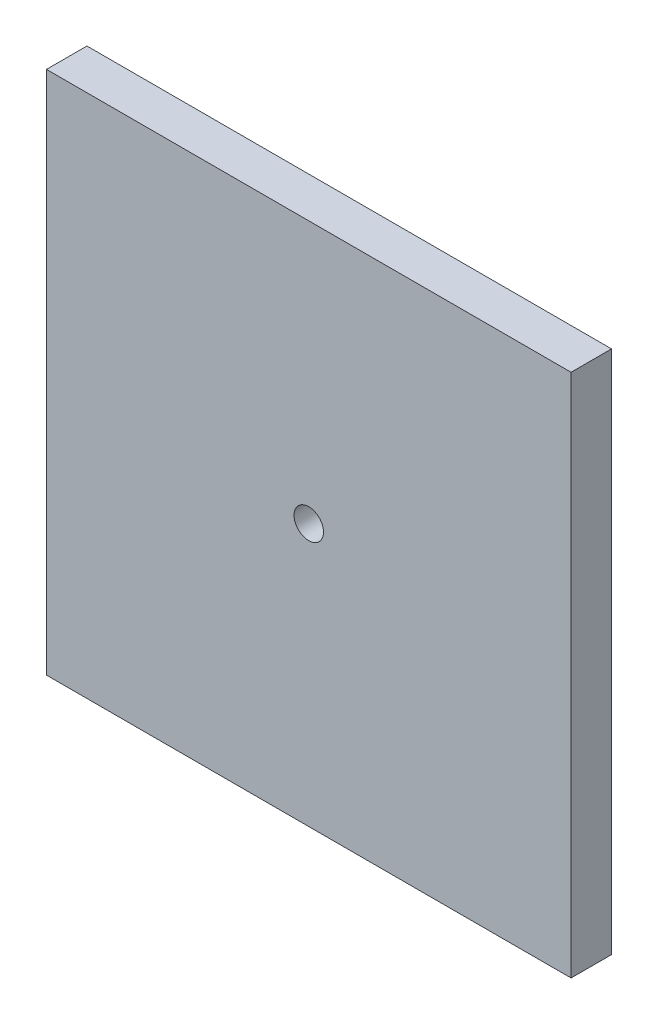
from build123d import *

# Parameters (mm, degrees)
SKETCH1_W           = 113.157
SKETCH1_H           = 113.157
SKETCH1_R           = 3.175
BOSS_EXTRUDE1_DEPTH = 8.73125
SKETCH1_5_R         = 3.175
BOSS_EXTRUDE4_DEPTH = 9.398


with BuildPart() as part:
    # Sketch1 → Boss-Extrude1 (new body)
    with BuildSketch(Plane.XY):
        Rectangle(SKETCH1_W, SKETCH1_H)
        Circle(SKETCH1_R, mode=Mode.SUBTRACT)
    extrude(amount=BOSS_EXTRUDE1_DEPTH)

    # Sketch1_5 → Boss-Extrude4 (add)
    with BuildSketch(Plane.XY):
        with Locations((-43.8785, 43.8785)):
            Circle(SKETCH1_5_R)
        with Locations((43.8785, 43.8785)):
            Circle(SKETCH1_5_R)
        with Locations((43.8785, -43.8785)):
            Circle(SKETCH1_5_R)
        with Locations((-43.8785, -43.8785)):
            Circle(SKETCH1_5_R)
    extrude(amount=-BOSS_EXTRUDE4_DEPTH)


solid = part.part
